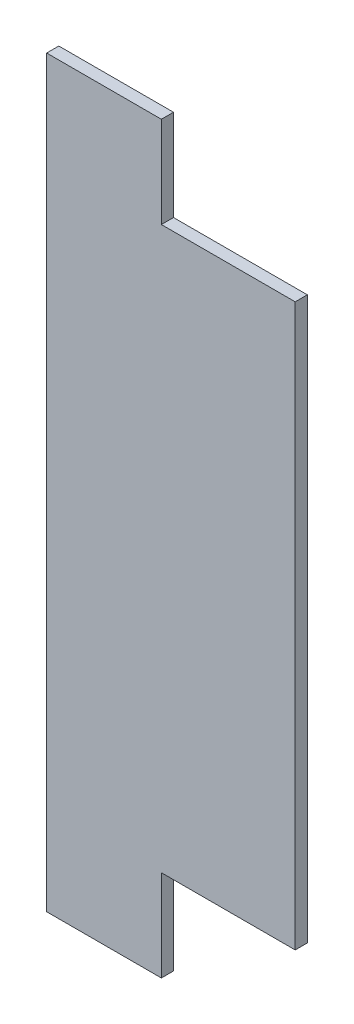
from build123d import *

# Parameters (mm, degrees)
SKETCH1_W           = 30
SKETCH1_H           = 194.5
BOSS_EXTRUDE1_DEPTH = 3.175
SKETCH2_W           = 35
SKETCH2_H           = 146.8
BOSS_EXTRUDE2_DEPTH = 3.175


with BuildPart() as part:
    # Sketch1 → Boss-Extrude1 (new body)
    with BuildSketch(Plane.XY):
        Rectangle(SKETCH1_W, SKETCH1_H)
    extrude(amount=BOSS_EXTRUDE1_DEPTH)

    # Sketch2 → Boss-Extrude2 (add)
    with BuildSketch(Plane.XY.offset(3.175)):
        with Locations((32.5, 0)):
            Rectangle(SKETCH2_W, SKETCH2_H)
    extrude(amount=-BOSS_EXTRUDE2_DEPTH)


solid = part.part
